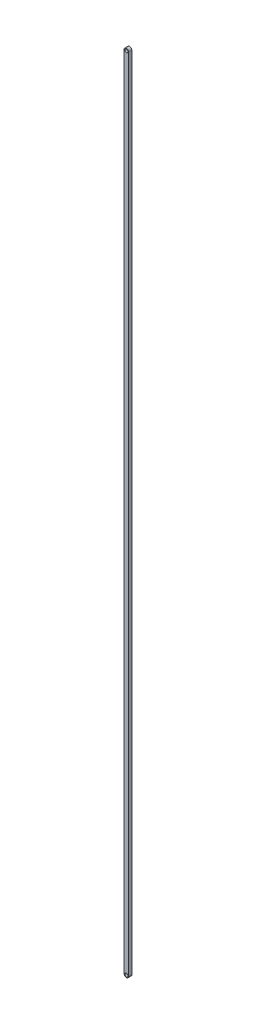
from build123d import *

# Parameters (mm, degrees)
SKETCH2_R           = 2.5
BOSS_EXTRUDE1_DEPTH = 2.5


with BuildPart() as part:
    # Sketch2 → Boss-Extrude1 (new body, symmetric)
    with BuildSketch(Plane.XY):
        with BuildLine():
            Line((3.5, 0), (3.5, -1244))
            ThreePointArc((3.5, -1244), (0, -1247.5), (-3.5, -1244))
            Line((-3.5, -1244), (-3.5, 0))
            ThreePointArc((-3.5, 0), (0, 3.5), (3.5, 0))
        make_face()
        Circle(SKETCH2_R, mode=Mode.SUBTRACT)
        with Locations((0, -1244)):
            Circle(SKETCH2_R, mode=Mode.SUBTRACT)
    extrude(amount=BOSS_EXTRUDE1_DEPTH, both=True)


solid = part.part
